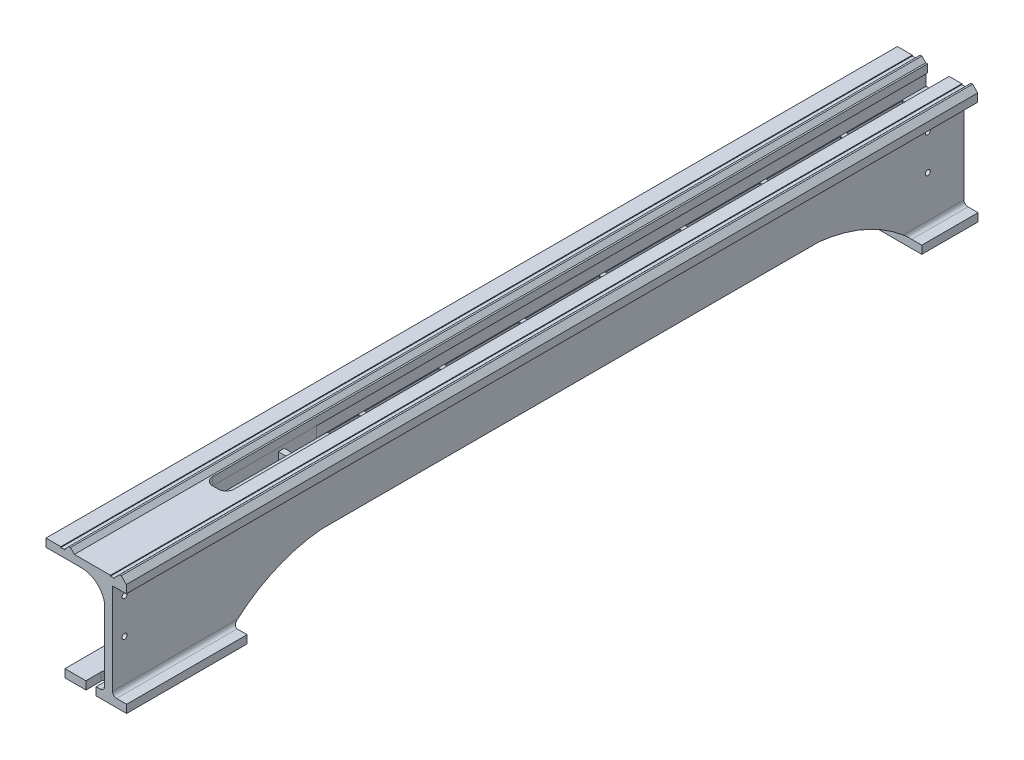
from build123d import *

# Parameters (mm, degrees)
BOSS_EXTRUDE1_DEPTH         = 1060
CUT_EXTRUDE1_DEPTH          = 800
SKETCH5_W                   = 10.426623187
SKETCH5_H                   = 125.292137731
BOSS_EXTRUDE2_DEPTH         = 950
SKETCH6_W                   = 7.435137382
SKETCH6_H                   = 64.029540506
BOSS_EXTRUDE3_DEPTH         = 50
LPATTERN1_COUNT             = 10
LPATTERN1_PITCH             = 100
CUT_EXTRUDE3_DEPTH          = 10
CUT_EXTRUDE3_DEPTH_BACK     = 100
CUT_EXTRUDE2_START          = -300
SKETCH3_W                   = 37.098457344
SKETCH3_H                   = 15
CUT_EXTRUDE2_DEPTH          = 1000
SKETCH7_W                   = 41.986295648
SKETCH7_H                   = 14.210937294
BOSS_EXTRUDE4_DEPTH         = 30
SKETCH8_R                   = 3.874254892
CUT_EXTRUDE4_DEPTH          = 30
SKETCH_1_R                  = 3.167509586
CUT_EXTRUDE_1_DEPTH         = 10
PATTERN_LINEAR_1_COUNT      = 2
PATTERN_LINEAR_1_PITCH      = 44
PATTERN_LINEAR_1_COUNT_DIR2 = 2
PATTERN_LINEAR_1_PITCH_DIR2 = 1000
SKETCH9_R                   = 6.088028913
CUT_EXTRUDE5_DEPTH          = 10
LPATTERN2_COUNT             = 2
LPATTERN2_PITCH             = 1005
CUT_EXTRUDE6_DEPTH          = 10


with BuildPart() as part:
    # Sketch1 → Boss-Extrude1 (new body)
    with BuildSketch(Plane.XY):
        with BuildLine():
            Line((-31.555119126, 31.290150882), (-37.853807036, 37.718722311))
            Line((-37.853807036, 37.718722311), (-39.853807036, 37.718722311))
            Line((-39.853807036, 37.718722311), (-46.282378465, 31.420034401))
            Line((-46.282378465, 31.420034401), (-46.282378465, 30.420034401))
            Line((-46.282378465, 30.420034401), (-51.282378465, 30.420034401))
            Line((-51.282378465, 30.420034401), (-51.282378465, 31.420034401))
            Line((-51.282378465, 31.420034401), (-96.206307824, 31.420034401))
            Line((-96.206307824, 31.420034401), (-101.105287309, 36.420034401))
            Line((-101.105287309, 36.420034401), (-103.105287309, 36.420034401))
            Line((-103.105287309, 36.420034401), (-108.055034777, 31.470286932))
            Line((-108.055034777, 31.470286932), (-108.055034777, 30.420034401))
            Line((-108.055034777, 30.420034401), (-113.055034777, 30.420034401))
            Line((-113.055034777, 30.420034401), (-113.055034777, 31.420034401))
            Line((-113.055034777, 31.420034401), (-131.555034777, 31.420034401))
            Line((-131.555034777, 31.420034401), (-131.555034777, 21.420034401))
            Line((-131.555034777, 21.420034401), (-87.349569261, 21.420034401))
            ThreePointArc((-87.349569261, 21.420034401), (-68.862935324, 14.835575372), (-58.701074529, -1.95273366))
            Line((-58.701074529, -1.95273366), (-58.701074529, -92.579965599))
            ThreePointArc((-58.701074529, -92.579965599), (-60.165540623, -96.115499505), (-63.701074529, -97.579965599))
            Line((-63.701074529, -97.579965599), (-108.009983562, -97.579965599))
            Line((-108.009983562, -97.579965599), (-108.009983562, -107.579965599))
            Line((-108.009983562, -107.579965599), (-31.195424592, -107.579965599))
            Line((-31.195424592, -107.579965599), (-31.195424592, -97.579965599))
            Line((-31.195424592, -97.579965599), (-43.701074529, -97.579965599))
            ThreePointArc((-43.701074529, -97.579965599), (-47.236608435, -96.115499505), (-48.701074529, -92.579965599))
            Line((-48.701074529, -92.579965599), (-48.701074529, 21.290150882))
            Line((-48.701074529, 21.290150882), (-31.555119126, 21.290150882))
            Line((-31.555119126, 21.290150882), (-31.555119126, 31.290150882))
        make_face()
    extrude(amount=BOSS_EXTRUDE1_DEPTH)

    # Sketch2 → Cut-Extrude1 (cut)
    with BuildSketch(Plane(origin=(0, 20.764722339, 0), x_dir=(1, 0, 0), z_dir=(0, 1, 0))):
        with BuildLine():
            Line((-84.170689991, 100), (-77.170689991, 100))
            ThreePointArc((-77.170689991, 100), (-70.099622179, 97.071067812), (-67.170689991, 90))
            Line((-67.170689991, 90), (-67.170689991, -890))
            ThreePointArc((-67.170689991, -890), (-70.099622179, -897.071067812), (-77.170689991, -900))
            Line((-77.170689991, -900), (-84.170689991, -900))
            ThreePointArc((-84.170689991, -900), (-91.241757803, -897.071067812), (-94.170689991, -890))
            Line((-94.170689991, -890), (-94.170689991, 90))
            ThreePointArc((-94.170689991, 90), (-91.241757803, 97.071067812), (-84.170689991, 100))
        make_face()
    extrude(amount=CUT_EXTRUDE1_DEPTH, mode=Mode.SUBTRACT)

    # Sketch5 → Boss-Extrude2 (add)
    with BuildSketch(Plane(origin=(0, 0, 0), x_dir=(-1, 0, 0), z_dir=(0, 0, -1))):
        with Locations((100.133130522, -34.849417223)):
            Rectangle(SKETCH5_W, SKETCH5_H)
    extrude(amount=-BOSS_EXTRUDE2_DEPTH)

    # Sketch6 → Boss-Extrude3 (add)
    with BuildSketch(Plane.ZY.offset(105.346442115)):
        with Locations((3.717568691, -15.430068515)):
            Rectangle(SKETCH6_W, SKETCH6_H)
    boss_extrude3 = extrude(amount=-BOSS_EXTRUDE3_DEPTH)

    # LPattern1: Boss-Extrude3 ×10
    with Locations(*[(0, 0, i * LPATTERN1_PITCH) for i in range(1, LPATTERN1_COUNT)]):
        add(boss_extrude3)

    # Sketch4 → Cut-Extrude3 (cut, two sides)
    with BuildSketch(Plane(origin=(-31.555119126, 0, 0), x_dir=(0, 0, -1), z_dir=(1, 0, 0))) as cut_extrude3_sk:
        with BuildLine():
            Line((-910, -97.579965599), (-910, -107.579965599))
            Line((-910, -107.579965599), (-910, -177.956634241))
            Line((-910, -177.956634241), (-70, -177.956634241))
            Line((-70, -177.956634241), (-70, -97.579965599))
            ThreePointArc((-70, -97.579965599), (-121.056751887, -63.823667059), (-180.068799532, -47.579965599))
            Line((-180.068799532, -47.579965599), (-800, -47.579965599))
            ThreePointArc((-800, -47.579965599), (-859.23910305, -63.253938888), (-910, -97.579965599))
        make_face()
    extrude(amount=CUT_EXTRUDE3_DEPTH, mode=Mode.SUBTRACT)
    extrude(cut_extrude3_sk.sketch, amount=-CUT_EXTRUDE3_DEPTH_BACK, mode=Mode.SUBTRACT)

    # Sketch3 → Cut-Extrude2 (cut)
    with BuildSketch(Plane.XY.offset(1060).offset(CUT_EXTRUDE2_START)):
        with Locations((-77.250303201, 13.920034401)):
            Rectangle(SKETCH3_W, SKETCH3_H)
    extrude(amount=-CUT_EXTRUDE2_DEPTH, mode=Mode.SUBTRACT)

    # Sketch7 → Boss-Extrude4 (add)
    with BuildSketch(Plane(origin=(0, 0, 0), x_dir=(-1, 0, 0), z_dir=(0, 0, -1))):
        with Locations((78.756733265, -0.685434246)):
            Rectangle(SKETCH7_W, SKETCH7_H)
    extrude(amount=-BOSS_EXTRUDE4_DEPTH)

    # Sketch8 → Cut-Extrude4 (cut)
    with BuildSketch(Plane(origin=(0, 6.420034401, 0), x_dir=(1, 0, 0), z_dir=(0, 1, 0))):
        with Locations((-79.789069173, -14.972288239)):
            Circle(SKETCH8_R)
    extrude(amount=-CUT_EXTRUDE4_DEPTH, mode=Mode.SUBTRACT)

    # Эскиз1 → Вырез-Вытянуть1 (cut)
    with BuildSketch(Plane(origin=(-48.701074529, 0, 0), x_dir=(0, 0, -1), z_dir=(1, 0, 0))):
        with Locations((-45, 3.290150882)):
            Circle(SKETCH_1_R)
    cut_extrude_1 = extrude(amount=-CUT_EXTRUDE_1_DEPTH, mode=Mode.SUBTRACT)

    # Линейный массив1: Cut-Extrude 1 2 × 2
    with Locations(*[(0, -i * PATTERN_LINEAR_1_PITCH, j * PATTERN_LINEAR_1_PITCH_DIR2) for i in range(PATTERN_LINEAR_1_COUNT) for j in range(PATTERN_LINEAR_1_COUNT_DIR2) if (i, j) != (0, 0)]):
        add(cut_extrude_1, mode=Mode.SUBTRACT)

    # Sketch9 → Cut-Extrude5 (cut)
    with BuildSketch(Plane.XZ.offset(107.579965599)):
        with Locations((-75.432174638, 36.066091654)):
            Circle(SKETCH9_R)
    cut_extrude5 = extrude(amount=-CUT_EXTRUDE5_DEPTH, mode=Mode.SUBTRACT)

    # LPattern2: Cut-Extrude5 ×2
    with Locations(*[(0, 0, i * LPATTERN2_PITCH) for i in range(1, LPATTERN2_COUNT)]):
        add(cut_extrude5, mode=Mode.SUBTRACT)

    # Sketch10 → Cut-Extrude6 (cut)
    with BuildSketch(Plane.XZ.offset(107.579965599)):
        with BuildLine():
            Line((-81.818611273, 1041.066091654), (-81.818611273, 1067.229436247))
            ThreePointArc((-81.818611273, 1067.229436247), (-75.432174638, 1073.615872882), (-69.045738002, 1067.229436247))
            Line((-69.045738002, 1067.229436247), (-69.045738002, 1041.066091654))
            ThreePointArc((-69.045738002, 1041.066091654), (-75.432174638, 1034.679655018), (-81.818611273, 1041.066091654))
        make_face()
    extrude(amount=-CUT_EXTRUDE6_DEPTH, mode=Mode.SUBTRACT)


solid = part.part
